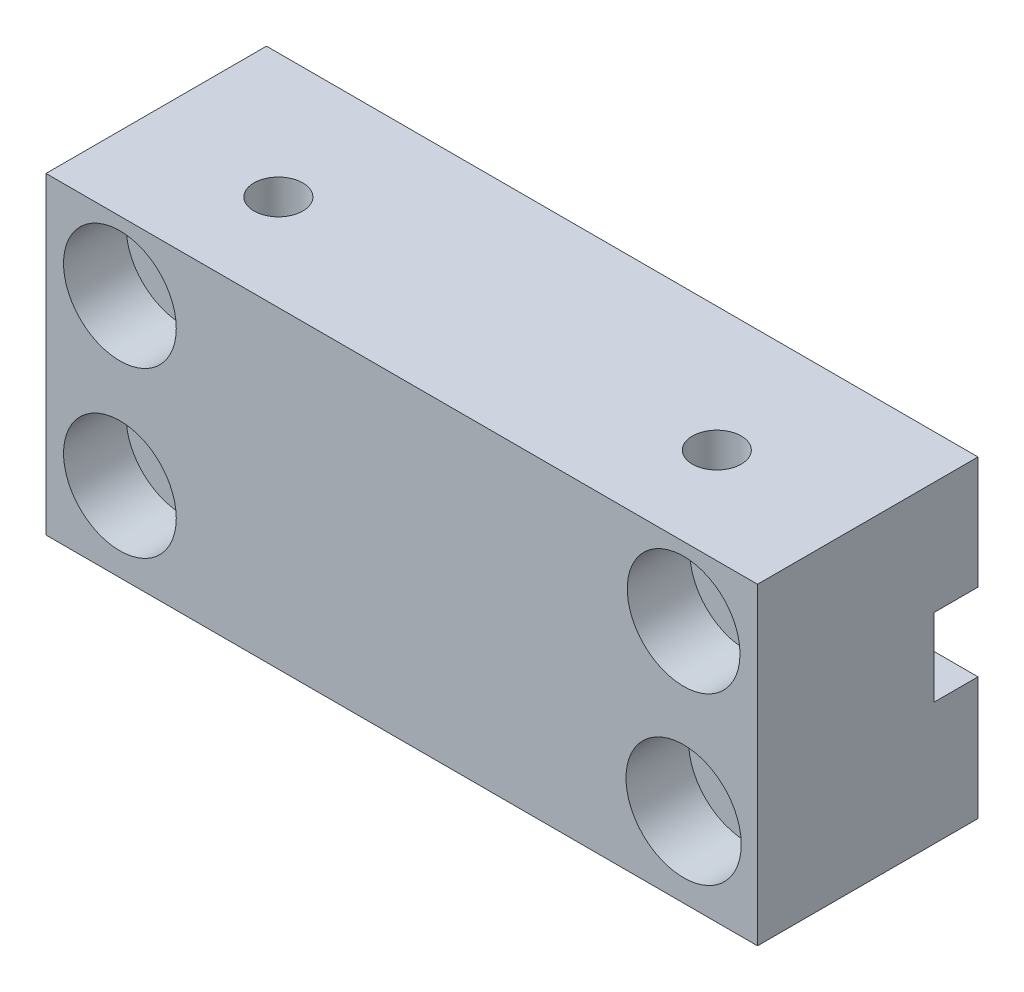
from build123d import *

# Parameters (mm, degrees)
SKETCH1_W           = 72.136
SKETCH1_H           = 31.75
SKETCH1_R           = 5.715
SKETCH1_R_2         = 5.842
BOSS_EXTRUDE1_DEPTH = 22.352
SKETCH4_R           = 5.715
SKETCH4_R_2         = 2.54
SKETCH4_R_3         = 5.842
BOSS_EXTRUDE2_DEPTH = 16.002
SKETCH2_R           = 2.4765
CUT_EXTRUDE1_DEPTH  = 32.75
SKETCH5_W           = 4.445
SKETCH5_H           = 7.874
CUT_EXTRUDE2_DEPTH  = 73.136


with BuildPart() as part:
    # Sketch1 → Boss-Extrude1 (new body)
    with BuildSketch(Plane.XY):
        Rectangle(SKETCH1_W, SKETCH1_H)
        with Locations((-28.575, 8.875537672)):
            Circle(SKETCH1_R, mode=Mode.SUBTRACT)
        with Locations((28.575, 8.875537672)):
            Circle(SKETCH1_R, mode=Mode.SUBTRACT)
        with Locations((-28.575, -7.8002595)):
            Circle(SKETCH1_R, mode=Mode.SUBTRACT)
        with Locations((28.575, -7.8002595)):
            Circle(SKETCH1_R_2, mode=Mode.SUBTRACT)
    extrude(amount=BOSS_EXTRUDE1_DEPTH)

    # Sketch4 → Boss-Extrude2 (add)
    with BuildSketch(Plane.XY):
        with Locations((-28.575, 8.875537672)):
            Circle(SKETCH4_R)
        with Locations((-28.575, 8.875537672)):
            Circle(SKETCH4_R_2, mode=Mode.SUBTRACT)
        with Locations((-28.575, -7.8002595)):
            Circle(SKETCH4_R)
        with Locations((-28.575, -7.8002595)):
            Circle(SKETCH4_R_2, mode=Mode.SUBTRACT)
        with Locations((28.575, 8.875537672)):
            Circle(SKETCH4_R)
        with Locations((28.575, 8.875537672)):
            Circle(SKETCH4_R_2, mode=Mode.SUBTRACT)
        with Locations((28.575, -7.8002595)):
            Circle(SKETCH4_R_3)
        with Locations((28.575, -7.8002595)):
            Circle(SKETCH4_R_2, mode=Mode.SUBTRACT)
    extrude(amount=BOSS_EXTRUDE2_DEPTH)

    # Sketch2 → Cut-Extrude1 (cut, through all)
    with BuildSketch(Plane.XZ.offset(15.875)):
        with Locations((-22.225, 12.6365)):
            Circle(SKETCH2_R)
        with Locations((22.225, 12.6365)):
            Circle(SKETCH2_R)
    extrude(amount=-CUT_EXTRUDE1_DEPTH, mode=Mode.SUBTRACT)

    # Sketch5 → Cut-Extrude2 (cut, through all)
    with BuildSketch(Plane.ZY.offset(36.068)):
        with Locations((2.2225, 0.508)):
            Rectangle(SKETCH5_W, SKETCH5_H)
    extrude(amount=-CUT_EXTRUDE2_DEPTH, mode=Mode.SUBTRACT)


solid = part.part
